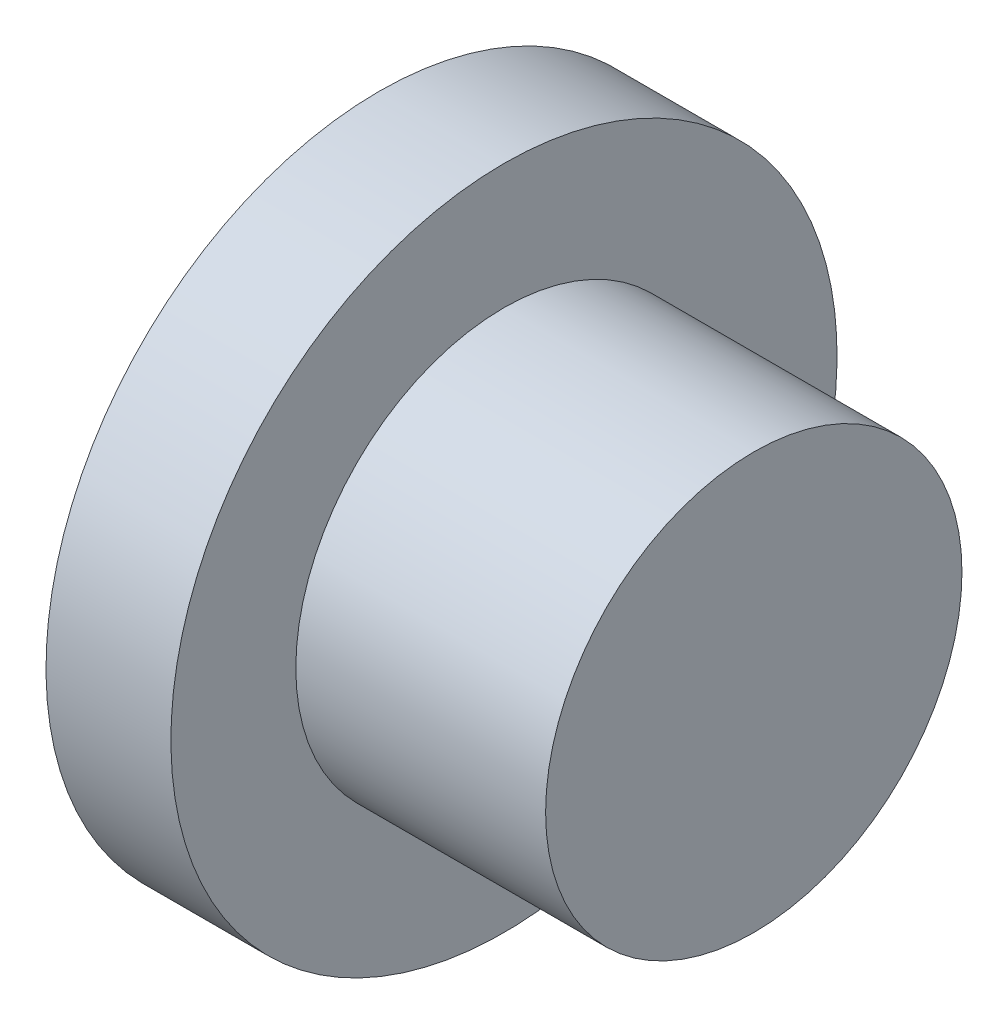
from build123d import *


with BuildPart() as part:
    # Esquisse1 → Révolution1 (revolve)
    with BuildSketch(Plane.XY):
        Polygon((0, 0), (0, 4), (1.5, 4), (1.5, 2.5), (4.5, 2.5), (4.5, 0), align=None)
    revolve(axis=Axis((4.5, 0, 0), (-1, 0, 0)))


solid = part.part
